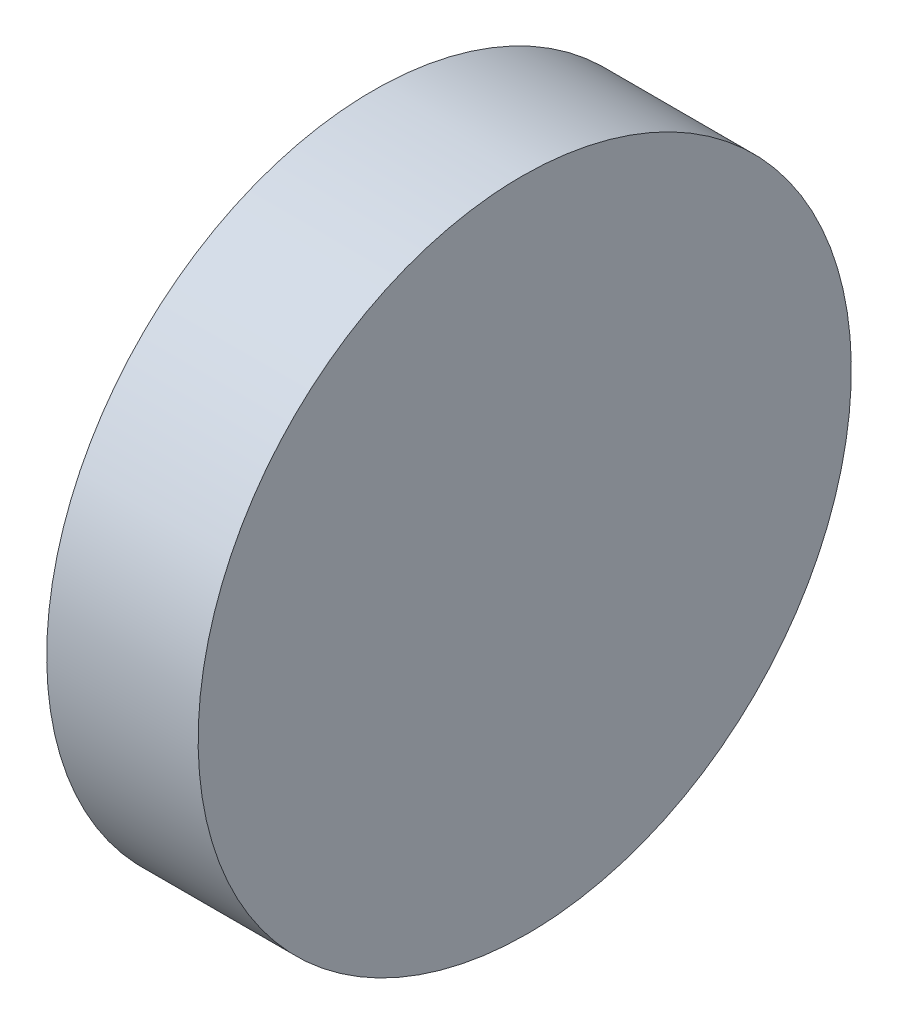
from build123d import *

# Parameters (mm, degrees)
EXTRUDE_1_DEPTH     = 12.7
CUT_EXTRUDE_1_DEPTH = 10


with BuildPart() as part:
    # 草图1 → 凸台-拉伸1 (new body)
    with BuildSketch(Plane.XY):
        Polygon((0, 6.35), (0, -6.35), (3, -6.35), (2.889168779, 6.35), align=None)
    extrude(amount=EXTRUDE_1_DEPTH)

    # 草图2 → 切除-拉伸1 (cut)
    with BuildSketch(Plane.ZY):
        with BuildLine():
            ThreePointArc((6.35, -6.35), (1.859871939, -4.490128061), (0, 0))
            Line((0, 0), (0, -6.35))
            Line((0, -6.35), (6.35, -6.35))
        make_face()
        with BuildLine():
            ThreePointArc((12.7, 0), (10.840128061, -4.490128061), (6.35, -6.35))
            Line((6.35, -6.35), (12.7, -6.35))
            Line((12.7, -6.35), (12.7, 0))
        make_face()
        with BuildLine():
            Line((12.7, 6.35), (6.35, 6.35))
            ThreePointArc((6.35, 6.35), (10.840128061, 4.490128061), (12.7, 0))
            Line((12.7, 0), (12.7, 6.35))
        make_face()
        with BuildLine():
            Line((6.35, 6.35), (0, 6.35))
            Line((0, 6.35), (0, 0))
            ThreePointArc((0, 0), (1.859871939, 4.490128061), (6.35, 6.35))
        make_face()
    extrude(amount=-CUT_EXTRUDE_1_DEPTH, mode=Mode.SUBTRACT)


solid = part.part
